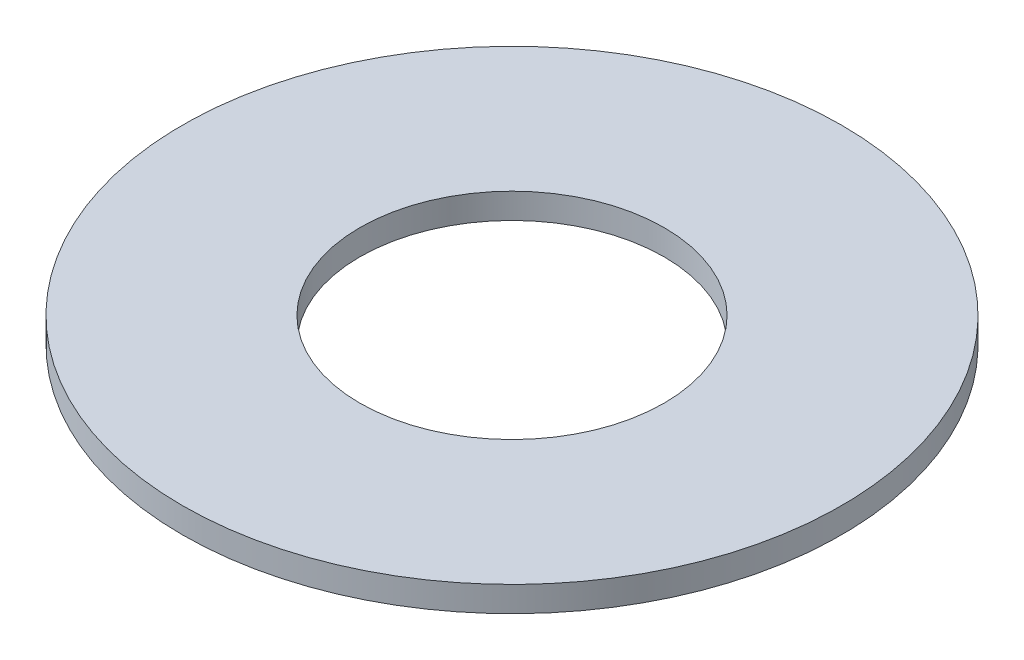
from build123d import *

# Parameters (mm, degrees)
SKETCH1_W = 7
SKETCH1_H = 1


with BuildPart() as part:
    # Sketch1 → Revolve1 (revolve)
    with BuildSketch(Plane(origin=(0, 0, 0), x_dir=(-1, 0, 0), z_dir=(0, 0, -1))):
        with Locations((-9.5, 0.5)):
            Rectangle(SKETCH1_W, SKETCH1_H)
    revolve(axis=Axis((0, 0, 0), (0, 1, 0)))


solid = part.part
